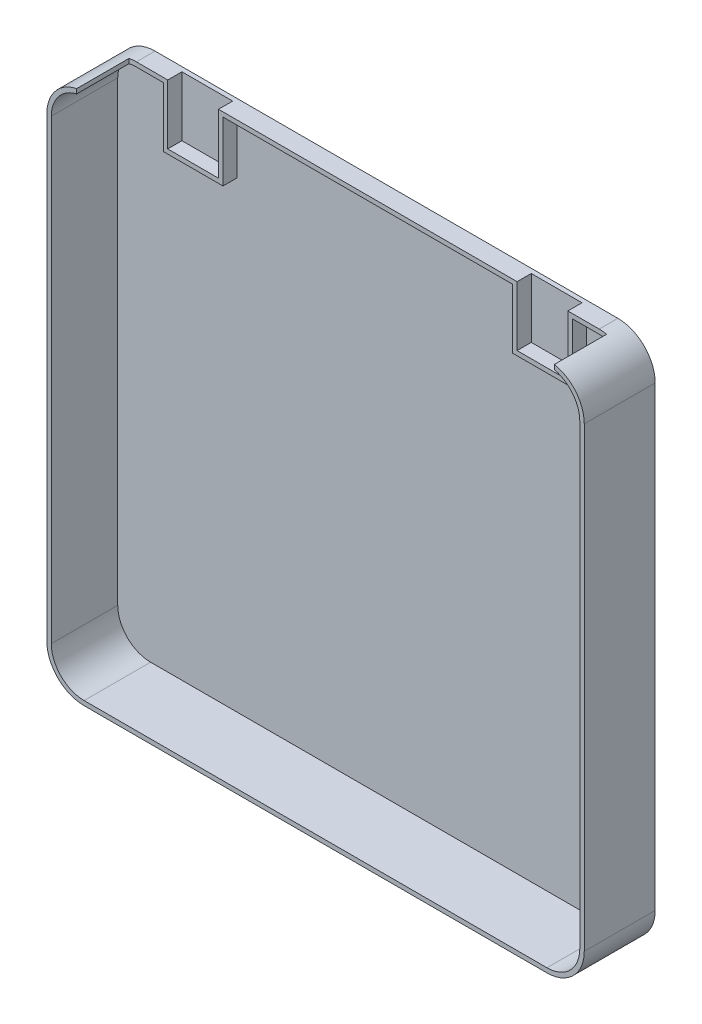
from build123d import *

# Parameters (mm, degrees)
ESQUISSE1_W             = 360
ESQUISSE1_H             = 356
BOSS_EXTRU_1_DEPTH      = 47.5
CONG_1_R                = 25
ENL_V_MAT_EXTRU_1_DEPTH = 44.5
ESQUISSE3_W             = 320
ESQUISSE3_H             = 35
ENL_V_MAT_EXTRU_2_DEPTH = 10
ESQUISSE5_W             = 40
ESQUISSE5_H             = 40
ESQUISSE5_W_2           = 34
ESQUISSE5_H_2           = 34
EXTRU_MINCE1_DEPTH      = 9.5
ESQUISSE10_W            = 34
ESQUISSE10_H            = 9.5
ENL_V_MAT_EXTRU_4_DEPTH = 10
ESQUISSE13_W            = 34
ESQUISSE13_H            = 9.5
ENL_V_MAT_EXTRU_5_DEPTH = 10


with BuildPart() as part:
    # Esquisse1 → Boss.-Extru.1 (new body)
    with BuildSketch(Plane.XY):
        with Locations((180, 178)):
            Rectangle(ESQUISSE1_W, ESQUISSE1_H)
    extrude(amount=BOSS_EXTRU_1_DEPTH)

    # Congé1
    cong_1_edges = [part.edges().sort_by_distance(p)[0] for p in [
        (0, 356, 23.75),
        (360, 356, 23.75),
        (360, 0, 23.75),
        (0, 0, 23.75),
    ]]
    fillet(cong_1_edges, radius=CONG_1_R)

    # Esquisse2 → Enlèv. mat.-Extru.1 (cut)
    with BuildSketch(Plane.XY.offset(47.5)):
        with BuildLine():
            Line((3, 331), (3, 25))
            ThreePointArc((3, 25), (9.443650814, 9.443650814), (25, 3))
            Line((25, 3), (335, 3))
            ThreePointArc((335, 3), (350.556349186, 9.443650814), (357, 25))
            Line((357, 25), (357, 331))
            ThreePointArc((357, 331), (350.556349186, 346.556349186), (335, 353))
            Line((335, 353), (25, 353))
            ThreePointArc((25, 353), (9.443650814, 346.556349186), (3, 331))
        make_face()
    extrude(amount=-ENL_V_MAT_EXTRU_1_DEPTH, mode=Mode.SUBTRACT)

    # Esquisse3 → Enlèv. mat.-Extru.2 (cut)
    with BuildSketch(Plane(origin=(0, 356, 0), x_dir=(1, 0, 0), z_dir=(0, 1, 0))):
        with Locations((180, -30)):
            Rectangle(ESQUISSE3_W, ESQUISSE3_H)
    extrude(amount=-ENL_V_MAT_EXTRU_2_DEPTH, mode=Mode.SUBTRACT)

    # Esquisse5 → Extru.-Mince1 (add)
    with BuildSketch(Plane.XY.offset(3)):
        with Locations((63, 333)):
            Rectangle(ESQUISSE5_W, ESQUISSE5_H)
        with Locations((63, 333)):
            Rectangle(ESQUISSE5_W_2, ESQUISSE5_H_2, mode=Mode.SUBTRACT)
        with Locations((297, 333)):
            Rectangle(ESQUISSE5_W, ESQUISSE5_H)
        with Locations((297, 333)):
            Rectangle(ESQUISSE5_W_2, ESQUISSE5_H_2, mode=Mode.SUBTRACT)
    extrude(amount=EXTRU_MINCE1_DEPTH)

    # Esquisse10 → Enlèv. mat.-Extru.4 (cut)
    with BuildSketch(Plane(origin=(0, 356, 0), x_dir=(1, 0, 0), z_dir=(0, 1, 0))):
        with Locations((297, -7.75)):
            Rectangle(ESQUISSE10_W, ESQUISSE10_H)
    extrude(amount=-ENL_V_MAT_EXTRU_4_DEPTH, mode=Mode.SUBTRACT)

    # Esquisse13 → Enlèv. mat.-Extru.5 (cut)
    with BuildSketch(Plane(origin=(0, 356, 0), x_dir=(1, 0, 0), z_dir=(0, 1, 0))):
        with Locations((63, -7.75)):
            Rectangle(ESQUISSE13_W, ESQUISSE13_H)
    extrude(amount=-ENL_V_MAT_EXTRU_5_DEPTH, mode=Mode.SUBTRACT)


solid = part.part
